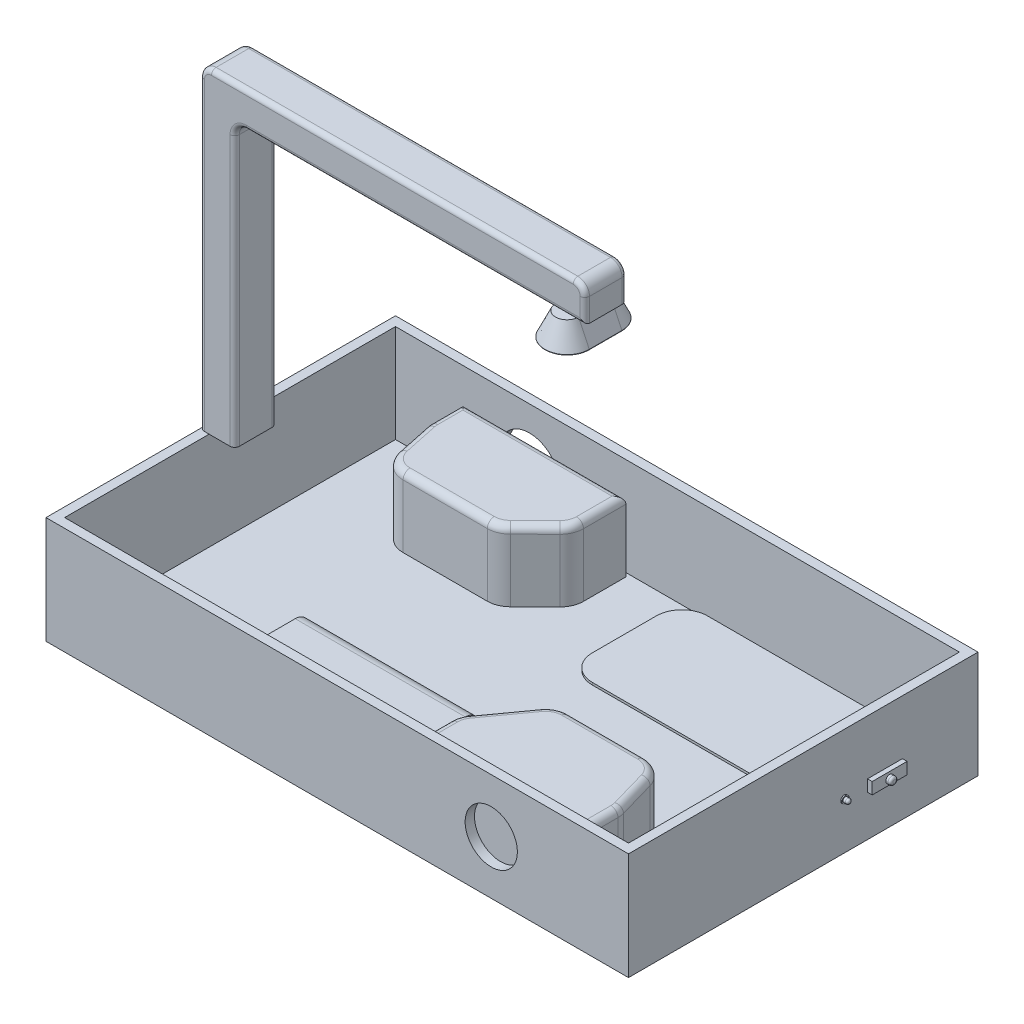
from build123d import *

# Parameters (mm, degrees)
SKETCH2_W            = 250
SKETCH2_H            = 150
BOSS_EXTRUDE1_DEPTH  = 4
SKETCH3_W            = 250
SKETCH3_H            = 150
SKETCH3_W_2          = 242
SKETCH3_H_2          = 142
BOSS_EXTRUDE2_DEPTH  = 42
BOSS_EXTRUDE3_DEPTH  = 9
FILLET1_R            = 5
FILLET2_R            = 5
FILLET3_R            = 2
BOSS_EXTRUDE4_DEPTH  = 10
BOSS_EXTRUDE4_TAPER  = -25
FILLET4_R            = 0.2
BOSS_EXTRUDE5_DEPTH  = 30
BOSS_EXTRUDE6_DEPTH  = 30
FILLET5_R            = 3
SKETCH8_R            = 11.211206803
CUT_EXTRUDE1_DEPTH   = 4
SKETCH9_R            = 12.977476732
CUT_EXTRUDE2_DEPTH   = 4
SKETCH10_W           = 15
SKETCH10_H           = 5
BOSS_EXTRUDE7_DEPTH  = 2
SKETCH11_R           = 1.66378252
BOSS_EXTRUDE8_DEPTH  = 2
FILLET6_R            = 1
SKETCH12_R           = 1.52303655
BOSS_EXTRUDE9_DEPTH  = 0.5
SKETCH13_R           = 1.057203078
BOSS_EXTRUDE10_DEPTH = 2
FILLET7_R            = 1
SKETCH14_W           = 33.089652655
SKETCH14_H           = 12.9995064
BOSS_EXTRUDE11_DEPTH = 3
BOSS_EXTRUDE12_DEPTH = 73
SKETCH16_W           = 62.417567968
SKETCH16_H           = 23.974959881
BOSS_EXTRUDE13_DEPTH = 13
BOSS_EXTRUDE13_TAPER = -25
SKETCH17_W           = 94.352024665
SKETCH17_H           = 49.435941067
BOSS_EXTRUDE14_DEPTH = 1
FILLET8_R            = 11


with BuildPart() as part:
    # Sketch2 → Boss-Extrude1 (new body)
    with BuildSketch(Plane(origin=(0, 0, 0), x_dir=(1, 0, 0), z_dir=(0, 1, 0))):
        Rectangle(SKETCH2_W, SKETCH2_H)
    extrude(amount=BOSS_EXTRUDE1_DEPTH)

    # Sketch3 → Boss-Extrude2 (add)
    with BuildSketch(Plane(origin=(0, 4, 0), x_dir=(1, 0, 0), z_dir=(0, 1, 0))):
        Rectangle(SKETCH3_W, SKETCH3_H)
        Rectangle(SKETCH3_W_2, SKETCH3_H_2, mode=Mode.SUBTRACT)
    extrude(amount=BOSS_EXTRUDE2_DEPTH)

    # Sketch4 → Boss-Extrude3 (add, symmetric)
    with BuildSketch(Plane.XY):
        Polygon((-110, 46), (-125, 46), (-125, 181.839263538), (40.259294234, 181.839263538), (40.259294234, 166.839263538), (-110, 166.839263538), align=None)
    extrude(amount=BOSS_EXTRUDE3_DEPTH, both=True)

    # Fillet1
    fillet1_edges = [part.edges().sort_by_distance(p)[0] for p in [
        (-110, 166.839263538, 0),
        (-125, 181.839263538, 0),
    ]]
    fillet(fillet1_edges, radius=FILLET1_R)

    # Fillet2
    fillet2_edges = [part.edges().sort_by_distance(p)[0] for p in [
        (40.259294234, 181.839263538, 0),
    ]]
    fillet(fillet2_edges, radius=FILLET2_R)

    # Fillet3
    fillet3_edges = [part.edges().sort_by_distance(p)[0] for p in [
        (-110, 103.919631769, -9),
        (-125, 111.419631769, 9),
        (-110, 103.919631769, 9),
        (-125, 111.419631769, -9),
        (-32.370352883, 166.839263538, -9),
        (-32.370352883, 166.839263538, 9),
        (-42.370352883, 181.839263538, -9),
        (-123.535533906, 180.374797444, -9),
        (-42.370352883, 181.839263538, 9),
        (-123.535533906, 180.374797444, 9),
        (-108.535533906, 165.374797444, -9),
        (-108.535533906, 165.374797444, 9),
        (40.259294234, 171.839263538, -9),
        (38.79482814, 180.374797444, -9),
        (40.259294234, 171.839263538, 9),
        (38.79482814, 180.374797444, 9),
    ]]
    fillet(fillet3_edges, radius=FILLET3_R)

    # Sketch5 → Boss-Extrude4 (add)
    with BuildSketch(Plane.XZ.offset(-166.839263538)):
        with BuildLine():
            ThreePointArc((35.616861921, 7), (30.648784635, 11.968077286), (25.680707349, 7))
            Line((25.680707349, 7), (25.680707349, -7))
            ThreePointArc((25.680707349, -7), (30.648784635, -11.968077286), (35.616861921, -7))
            Line((35.616861921, -7), (35.616861921, 7))
        make_face()
    extrude(amount=BOSS_EXTRUDE4_DEPTH, taper=BOSS_EXTRUDE4_TAPER)

    # Fillet4
    fillet4_edges = [part.edges().sort_by_distance(p)[0] for p in [
        (30.648784635, 156.839263538, 16.631153867),
        (21.017630768, 156.839263538, 0),
        (30.648784635, 156.839263538, -16.631153867),
        (40.279938503, 156.839263538, 0),
    ]]
    fillet(fillet4_edges, radius=FILLET4_R)

    # Sketch6 → Boss-Extrude5 (add)
    with BuildSketch(Plane(origin=(0, 4, 0), x_dir=(1, 0, 0), z_dir=(0, 1, 0))):
        with BuildLine():
            Line((-90.500469276, 69.421053969), (-20.500469276, 69.421053969))
            Line((-20.500469276, 69.421053969), (-20.500469276, 51.178140996))
            ThreePointArc((-20.500469276, 51.178140996), (-21.273909584, 47.321899788), (-23.474588526, 44.062173058))
            Line((-23.474588526, 44.062173058), (-34.186085203, 33.486282475))
            ThreePointArc((-34.186085203, 33.486282475), (-37.414577335, 31.35131318), (-41.211965952, 30.602250413))
            Line((-41.211965952, 30.602250413), (-77.341485247, 30.602250413))
            ThreePointArc((-77.341485247, 30.602250413), (-83.642237261, 32.836909206), (-87.126983096, 38.542145602))
            Line((-87.126983096, 38.542145602), (-90.285967126, 53.547319741))
            ThreePointArc((-90.285967126, 53.547319741), (-90.446699177, 54.571803603), (-90.500469276, 55.607424552))
            Line((-90.500469276, 55.607424552), (-90.500469276, 69.421053969))
        make_face()
    extrude(amount=BOSS_EXTRUDE5_DEPTH)

    # Sketch7 → Boss-Extrude6 (add)
    with BuildSketch(Plane(origin=(0, 4, 0), x_dir=(1, 0, 0), z_dir=(0, 1, 0))):
        with BuildLine():
            Line((94.272789683, -67.986149324), (24.272789683, -67.986149324))
            Line((24.272789683, -67.986149324), (24.272789683, -50.632607903))
            ThreePointArc((24.272789683, -50.632607903), (24.756935344, -47.558764024), (26.162492922, -44.78255778))
            Line((26.162492922, -44.78255778), (39.037934791, -26.932513371))
            ThreePointArc((39.037934791, -26.932513371), (42.593042271, -23.880302511), (47.148231552, -22.782563494))
            Line((47.148231552, -22.782563494), (79.692982564, -22.782563494))
            ThreePointArc((79.692982564, -22.782563494), (85.714393401, -24.79866648), (89.307847365, -30.034041189))
            Line((89.307847365, -30.034041189), (93.887654484, -46.055095912))
            ThreePointArc((93.887654484, -46.055095912), (94.176037837, -47.415930934), (94.272789683, -48.803618217))
            Line((94.272789683, -48.803618217), (94.272789683, -67.986149324))
        make_face()
    extrude(amount=BOSS_EXTRUDE6_DEPTH)

    # Fillet5
    fillet5_edges = [part.edges().sort_by_distance(p)[0] for p in [
        (-90.500469276, 34, -62.51423926),
        (-90.446699177, 34, -54.571803603),
        (-88.706475111, 34, -46.044732672),
        (-83.642237261, 34, -32.836909206),
        (-59.276725599, 34, -30.602250413),
        (-37.414577335, 34, -31.35131318),
        (-28.830336864, 34, -38.774227767),
        (-21.273909584, 34, -47.321899788),
        (-20.500469276, 34, -60.299597482),
        (-55.500469276, 34, -69.421053969),
        (94.272789683, 34, 58.394883771),
        (94.176037837, 34, 47.415930934),
        (91.597750924, 34, 38.04456855),
        (85.714393401, 34, 24.79866648),
        (63.420607058, 34, 22.782563494),
        (42.593042271, 34, 23.880302511),
        (32.600213856, 34, 35.857535576),
        (24.756935344, 34, 47.558764024),
        (24.272789683, 34, 59.309378614),
        (59.272789683, 34, 67.986149324),
    ]]
    fillet(fillet5_edges, radius=FILLET5_R)

    # Sketch8 → Cut-Extrude1 (cut)
    with BuildSketch(Plane.XY.offset(75)):
        with Locations((66.095760029, 22.882433169)):
            Circle(SKETCH8_R)
    extrude(amount=-CUT_EXTRUDE1_DEPTH, mode=Mode.SUBTRACT)

    # Sketch9 → Cut-Extrude2 (cut)
    with BuildSketch(Plane(origin=(0, 0, -75), x_dir=(-1, 0, 0), z_dir=(0, 0, -1))):
        with Locations((63.515768044, 22.215170496)):
            Circle(SKETCH9_R)
    extrude(amount=-CUT_EXTRUDE2_DEPTH, mode=Mode.SUBTRACT)

    # Sketch10 → Boss-Extrude7 (add)
    with BuildSketch(Plane(origin=(125, 0, 0), x_dir=(0, 0, -1), z_dir=(1, 0, 0))):
        with Locations((35.079187759, 20.095773873)):
            Rectangle(SKETCH10_W, SKETCH10_H)
    extrude(amount=BOSS_EXTRUDE7_DEPTH)

    # Sketch11 → Boss-Extrude8 (add)
    with BuildSketch(Plane(origin=(127, 0, 0), x_dir=(0, 0, -1), z_dir=(1, 0, 0))):
        with Locations((35.079187759, 19.812546088)):
            Circle(SKETCH11_R)
    extrude(amount=BOSS_EXTRUDE8_DEPTH)

    # Fillet6
    fillet6_edges = [part.edges().sort_by_distance(p)[0] for p in [
        (129, 19.812546088, -33.415405238),
    ]]
    fillet(fillet6_edges, radius=FILLET6_R)

    # Sketch12 → Boss-Extrude9 (add)
    with BuildSketch(Plane(origin=(125, 0, 0), x_dir=(0, 0, -1), z_dir=(1, 0, 0))):
        with Locations((17.613460865, 20.095773873)):
            Circle(SKETCH12_R)
    extrude(amount=BOSS_EXTRUDE9_DEPTH)

    # Sketch13 → Boss-Extrude10 (add)
    with BuildSketch(Plane(origin=(125.5, 0, 0), x_dir=(0, 0, -1), z_dir=(1, 0, 0))):
        with Locations((17.613460865, 20.095773873)):
            Circle(SKETCH13_R)
    extrude(amount=BOSS_EXTRUDE10_DEPTH)

    # Fillet7
    fillet7_edges = [part.edges().sort_by_distance(p)[0] for p in [
        (127.5, 20.095773873, -16.556257788),
    ]]
    fillet(fillet7_edges, radius=FILLET7_R)

    # Sketch14 → Boss-Extrude11 (add)
    with BuildSketch(Plane(origin=(0, 4, 0), x_dir=(1, 0, 0), z_dir=(0, 1, 0))):
        with Locations((-48.352002285, -46.540906524)):
            Rectangle(SKETCH14_W, SKETCH14_H)
    extrude(amount=BOSS_EXTRUDE11_DEPTH)

    # Sketch15 → Boss-Extrude12 (add)
    with BuildSketch(Plane.ZY.offset(64.896828612)):
        with BuildLine():
            Line((64.768088921, 3.004320132), (28.148227328, 3.004320132))
            ThreePointArc((28.148227328, 3.004320132), (22.131276685, 9.021270775), (28.148227328, 15.038221418))
            Line((28.148227328, 15.038221418), (64.768088921, 15.038221418))
            ThreePointArc((64.768088921, 15.038221418), (70.785039563, 9.021270775), (64.768088921, 3.004320132))
        make_face()
    extrude(amount=-BOSS_EXTRUDE12_DEPTH)

    # Sketch16 → Boss-Extrude13 (add)
    with BuildSketch(Plane(origin=(0, 4, 0), x_dir=(1, 0, 0), z_dir=(0, 1, 0))):
        with Locations((61.730719015, 34.515675002)):
            Rectangle(SKETCH16_W, SKETCH16_H)
    extrude(amount=BOSS_EXTRUDE13_DEPTH, taper=BOSS_EXTRUDE13_TAPER)

    # Sketch17 → Boss-Extrude14 (add)
    with BuildSketch(Plane(origin=(0, 17, 0), x_dir=(1, 0, 0), z_dir=(0, 1, 0))):
        with Locations((61.687687098, 33.693794126)):
            Rectangle(SKETCH17_W, SKETCH17_H)
    extrude(amount=BOSS_EXTRUDE14_DEPTH)

    # Fillet8
    fillet8_edges = [part.edges().sort_by_distance(p)[0] for p in [
        (14.511674765, 17.5, -58.411764659),
        (14.511674765, 17.5, -8.975823592),
        (108.86369943, 17.5, -8.975823592),
        (108.86369943, 17.5, -58.411764659),
    ]]
    fillet(fillet8_edges, radius=FILLET8_R)


solid = part.part
